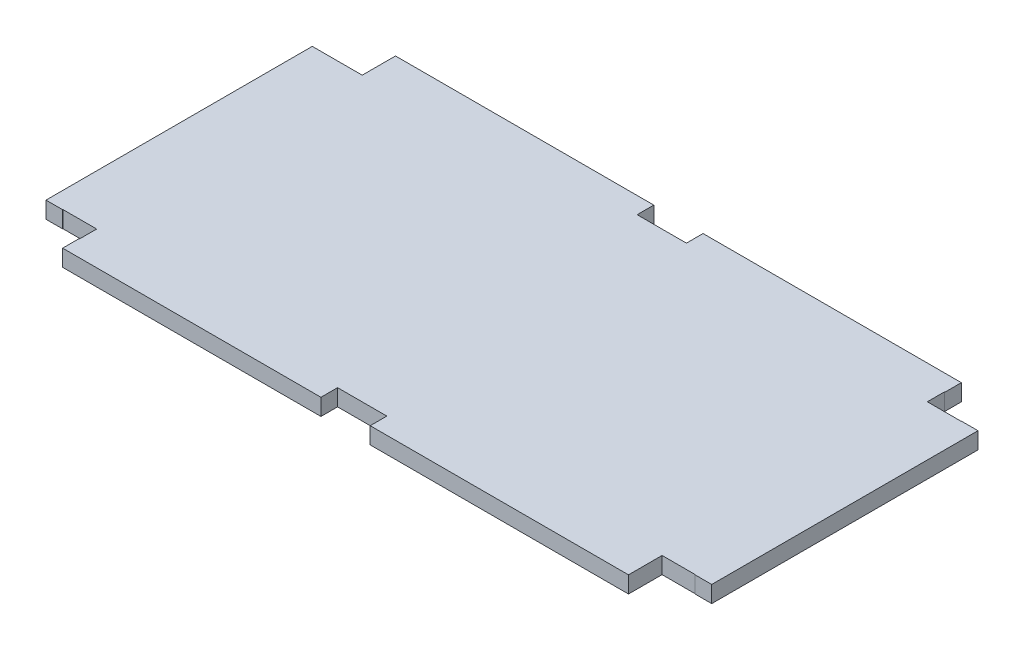
from build123d import *

# Parameters (mm, degrees)
SKETCH1_W               = 254
SKETCH1_H               = 127
BOSS_EXTRUDE1_DEPTH     = 6.35
CUT_EXTRUDE1_DEPTH      = 143.132235964
CUT_EXTRUDE1_DEPTH_BACK = 6.35
SKETCH2_W               = 18.796
SKETCH2_H               = 6.35
CUT_EXTRUDE3_DEPTH      = 127
CUT_EXTRUDE3_DEPTH_BACK = 127
SKETCH3_W               = 12.876244412
SKETCH3_H               = 6.459801397
SKETCH3_W_2             = 12.7
SKETCH3_H_2             = 6.35
CUT_EXTRUDE4_DEPTH      = 127
CUT_EXTRUDE4_DEPTH_BACK = 127
SKETCH4_W               = 12.876244412
SKETCH4_H               = 6.459801397


with BuildPart() as part:
    # Sketch1 → Boss-Extrude1 (new body)
    with BuildSketch(Plane(origin=(0, 0, 0), x_dir=(1, 0, 0), z_dir=(0, 1, 0))):
        Rectangle(SKETCH1_W, SKETCH1_H)
    extrude(amount=BOSS_EXTRUDE1_DEPTH)

    # Sketch2 → Cut-Extrude1 (cut, two sides: drawn at the far end of the back side and taken through both)
    with BuildSketch(Plane(origin=(0, 0, 0), x_dir=(1, 0, 0), z_dir=(0, 1, 0)).offset(-CUT_EXTRUDE1_DEPTH_BACK)):
        Polygon((-107.95, -63.5), (-107.95, -57.15), (-120.65, -57.15), (-120.65, -50.8), (-127, -50.8), (-127, -63.5), align=None)
        with Locations((0, -60.325)):
            Rectangle(SKETCH2_W, SKETCH2_H)
        Polygon((-127, 50.8), (-120.65, 50.8), (-120.65, 57.15), (-107.95, 57.15), (-107.95, 63.5), (-127, 63.5), align=None)
        with Locations((0, 60.325)):
            Rectangle(SKETCH2_W, SKETCH2_H)
        Polygon((107.95, -63.5), (107.95, -57.15), (120.65, -57.15), (120.65, -50.8), (127, -50.8), (127, -63.5), align=None)
        Polygon((127, 50.8), (120.65, 50.8), (120.65, 57.15), (107.95, 57.15), (107.95, 63.5), (127, 63.5), align=None)
    extrude(amount=CUT_EXTRUDE1_DEPTH + CUT_EXTRUDE1_DEPTH_BACK, mode=Mode.SUBTRACT)

    # Sketch3 → Cut-Extrude3 (cut, two sides: drawn at the far end of the back side and taken through both)
    with BuildSketch(Plane(origin=(0, 0, 0), x_dir=(1, 0, 0), z_dir=(0, 1, 0)).offset(-CUT_EXTRUDE3_DEPTH_BACK)):
        with Locations((-114.211877794, -53.920099302)):
            Rectangle(SKETCH3_W, SKETCH3_H)
        with Locations((-114.3, 53.975)):
            Rectangle(SKETCH3_W_2, SKETCH3_H_2)
        with Locations((114.3, -53.920099302)):
            Rectangle(SKETCH3_W_2, SKETCH3_H)
    extrude(amount=CUT_EXTRUDE3_DEPTH + CUT_EXTRUDE3_DEPTH_BACK, mode=Mode.SUBTRACT)

    # Sketch4 → Cut-Extrude4 (cut, two sides: drawn at the far end of the back side and taken through both)
    with BuildSketch(Plane(origin=(0, 0, 0), x_dir=(-1, 0, 0), z_dir=(0, -1, 0)).offset(-CUT_EXTRUDE4_DEPTH_BACK)):
        with Locations((-114.211877794, 53.920099302)):
            Rectangle(SKETCH4_W, SKETCH4_H)
    extrude(amount=CUT_EXTRUDE4_DEPTH + CUT_EXTRUDE4_DEPTH_BACK, mode=Mode.SUBTRACT)


solid = part.part
